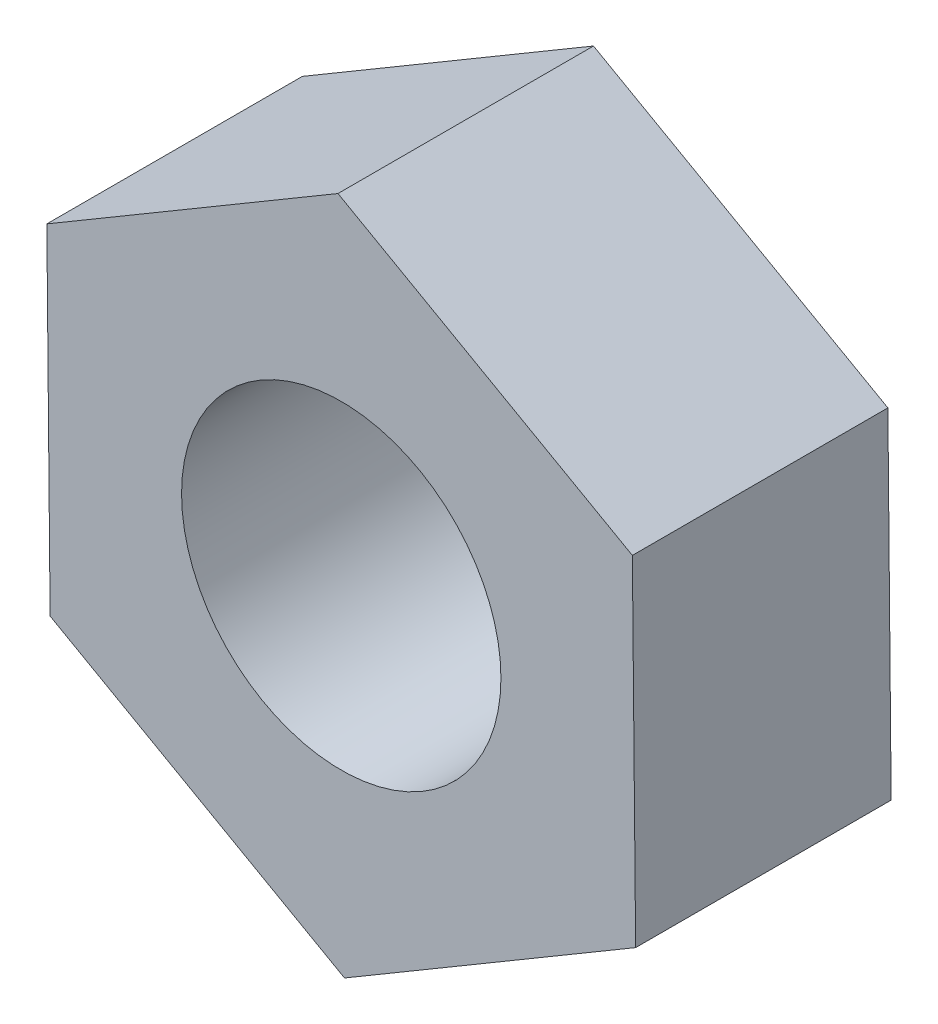
from build123d import *

# Parameters (mm, degrees)
SKETCH_1_R      = 1.5
EXTRUDE_1_DEPTH = 2.4


with BuildPart() as part:
    # 草图1 → 凸台-拉伸1 (new body)
    with BuildSketch(Plane.XY):
        Polygon((-3.620507368, 22.543352329), (-3.651242141, 25.718630066), (-6.416480712, 27.27965184), (-9.15098451, 25.665395877), (-9.120249737, 22.49011814), (-6.355011166, 20.929096366), align=None)
        with Locations((-6.385745939, 24.104374103)):
            Circle(SKETCH_1_R, mode=Mode.SUBTRACT)
    extrude(amount=EXTRUDE_1_DEPTH)


solid = part.part
